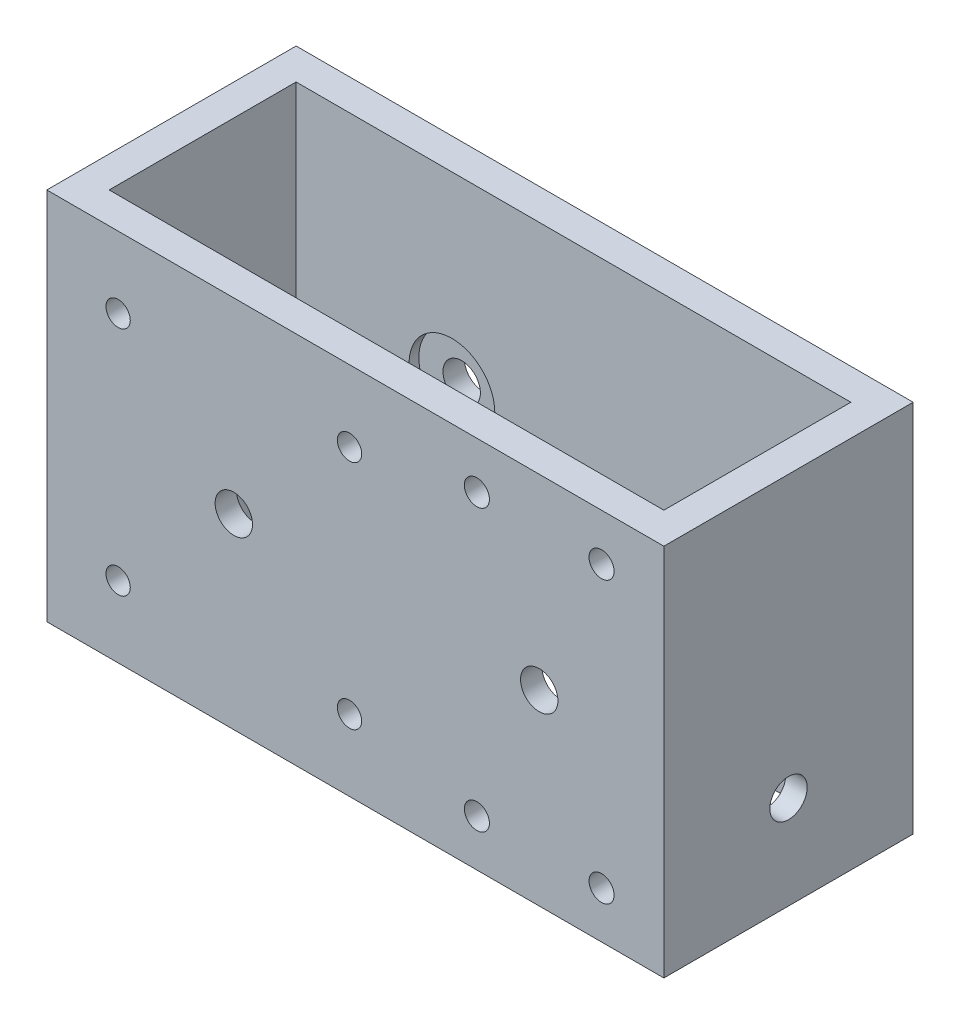
from build123d import *

# Parameters (mm, degrees)
SKETCH1_W           = 125.73
SKETCH1_H           = 50.8
SKETCH1_W_2         = 113.03
SKETCH1_H_2         = 38.1
BOSS_EXTRUDE1_DEPTH = 76.2
CUT_EXTRUDE1_REACH  = 157.548
SKETCH2_R           = 2.4765
SKETCH2_5_R         = 3.81
CUT_EXTRUDE2_DEPTH  = 156.547783334
SKETCH5_R           = 3.81
CUT_EXTRUDE4_DEPTH  = 156.547783334
SKETCH6_R           = 3.81
CUT_EXTRUDE5_DEPTH  = 156.547783334
SKETCH7_R           = 8.73125
CUT_EXTRUDE6_DEPTH  = 1.984375
SKETCH8_R           = 8.73125
CUT_EXTRUDE7_DEPTH  = 1.984375
CUT_EXTRUDE8_START  = -1.984375
SKETCH9_R           = 8.73125
CUT_EXTRUDE8_DEPTH  = 1.984375
CUT_EXTRUDE9_START  = -1.984375
SKETCH10_R          = 8.73125
CUT_EXTRUDE9_DEPTH  = 1.984375
SKETCH12_R          = 2.5527
CUT_EXTRUDE11_DEPTH = 154.591260819


with BuildPart() as part:
    # Sketch1 → Boss-Extrude1 (new body)
    with BuildSketch(Plane(origin=(0, 0, 0), x_dir=(1, 0, 0), z_dir=(0, 1, 0))):
        with Locations((62.865, -25.4)):
            Rectangle(SKETCH1_W, SKETCH1_H)
        with Locations((62.865, -25.4)):
            Rectangle(SKETCH1_W_2, SKETCH1_H_2, mode=Mode.SUBTRACT)
    extrude(amount=BOSS_EXTRUDE1_DEPTH)

    # Sketch2 → Cut-Extrude1 (cut, up to next)
    with BuildSketch(Plane.XY.offset(50.8), mode=Mode.PRIVATE) as cut_extrude1_sk1:
        with Locations((14.526827682, 61.673172318)):
            Circle(SKETCH2_R)
    cut_extrude1_tool1 = extrude(cut_extrude1_sk1.sketch, amount=-CUT_EXTRUDE1_REACH, mode=Mode.PRIVATE) & part.part
    # Sketch2 → Cut-Extrude1 (cut, up to next)
    with BuildSketch(Plane.XY.offset(50.8), mode=Mode.PRIVATE) as cut_extrude1_sk2:
        with Locations((61.673172318, 61.673172318)):
            Circle(SKETCH2_R)
    cut_extrude1_tool2 = extrude(cut_extrude1_sk2.sketch, amount=-CUT_EXTRUDE1_REACH, mode=Mode.PRIVATE) & part.part
    # Sketch2 → Cut-Extrude1 (cut, up to next)
    with BuildSketch(Plane.XY.offset(50.8), mode=Mode.PRIVATE) as cut_extrude1_sk3:
        with Locations((61.673172318, 14.526827682)):
            Circle(SKETCH2_R)
    cut_extrude1_tool3 = extrude(cut_extrude1_sk3.sketch, amount=-CUT_EXTRUDE1_REACH, mode=Mode.PRIVATE) & part.part
    # Sketch2 → Cut-Extrude1 (cut, up to next)
    with BuildSketch(Plane.XY.offset(50.8), mode=Mode.PRIVATE) as cut_extrude1_sk4:
        with Locations((14.526827682, 14.526827682)):
            Circle(SKETCH2_R)
    cut_extrude1_tool4 = extrude(cut_extrude1_sk4.sketch, amount=-CUT_EXTRUDE1_REACH, mode=Mode.PRIVATE) & part.part
    add(cut_extrude1_tool1.solids().sort_by_distance((14.526828, 61.673172, 50.8))[0], mode=Mode.SUBTRACT)
    add(cut_extrude1_tool2.solids().sort_by_distance((61.673172, 61.673172, 50.8))[0], mode=Mode.SUBTRACT)
    add(cut_extrude1_tool3.solids().sort_by_distance((61.673172, 14.526828, 50.8))[0], mode=Mode.SUBTRACT)
    add(cut_extrude1_tool4.solids().sort_by_distance((14.526828, 14.526828, 50.8))[0], mode=Mode.SUBTRACT)

    # Sketch2_5 → Cut-Extrude2 (cut, through all)
    with BuildSketch(Plane.XY.offset(50.8)):
        with Locations((38.1, 38.1)):
            Circle(SKETCH2_5_R)
    extrude(amount=-CUT_EXTRUDE2_DEPTH, mode=Mode.SUBTRACT)

    # Sketch5 → Cut-Extrude4 (cut, through all)
    with BuildSketch(Plane.XY.offset(50.8)):
        with Locations((100.33, 38.1)):
            Circle(SKETCH5_R)
    extrude(amount=-CUT_EXTRUDE4_DEPTH, mode=Mode.SUBTRACT)

    # Sketch6 → Cut-Extrude5 (cut, through all)
    with BuildSketch(Plane.ZY):
        with Locations((25.4, 19.05)):
            Circle(SKETCH6_R)
    extrude(amount=-CUT_EXTRUDE5_DEPTH, mode=Mode.SUBTRACT)

    # Sketch7 → Cut-Extrude6 (cut)
    with BuildSketch(Plane(origin=(6.35, 0, 0), x_dir=(0, 0, -1), z_dir=(1, 0, 0))):
        with Locations((-25.4, 19.05)):
            Circle(SKETCH7_R)
    extrude(amount=-CUT_EXTRUDE6_DEPTH, mode=Mode.SUBTRACT)

    # Sketch8 → Cut-Extrude7 (cut)
    with BuildSketch(Plane(origin=(0, 0, 44.45), x_dir=(-1, 0, 0), z_dir=(0, 0, -1))):
        with Locations((-38.1, 38.1)):
            Circle(SKETCH8_R)
        with Locations((-100.33, 38.1)):
            Circle(SKETCH8_R)
    extrude(amount=-CUT_EXTRUDE7_DEPTH, mode=Mode.SUBTRACT)

    # Sketch9 → Cut-Extrude8 (cut)
    with BuildSketch(Plane.ZY.offset(-119.38).offset(CUT_EXTRUDE8_START)):
        with Locations((25.4, 19.05)):
            Circle(SKETCH9_R)
    extrude(amount=CUT_EXTRUDE8_DEPTH, mode=Mode.SUBTRACT)

    # Sketch10 → Cut-Extrude9 (cut)
    with BuildSketch(Plane.XY.offset(6.35).offset(CUT_EXTRUDE9_START)):
        with Locations((38.1, 38.1)):
            Circle(SKETCH10_R)
        with Locations((100.33, 38.1)):
            Circle(SKETCH10_R)
    extrude(amount=CUT_EXTRUDE9_DEPTH, mode=Mode.SUBTRACT)

    # Sketch12 → Cut-Extrude11 (cut, through all)
    with BuildSketch(Plane(origin=(0, 0, 44.45), x_dir=(-1, 0, 0), z_dir=(0, 0, -1))):
        with Locations((-87.63, 9.525)):
            Circle(SKETCH12_R)
        with Locations((-113.03, 9.525)):
            Circle(SKETCH12_R)
        with Locations((-113.03, 66.675)):
            Circle(SKETCH12_R)
        with Locations((-87.63, 66.675)):
            Circle(SKETCH12_R)
    extrude(amount=-CUT_EXTRUDE11_DEPTH, mode=Mode.SUBTRACT)


solid = part.part
